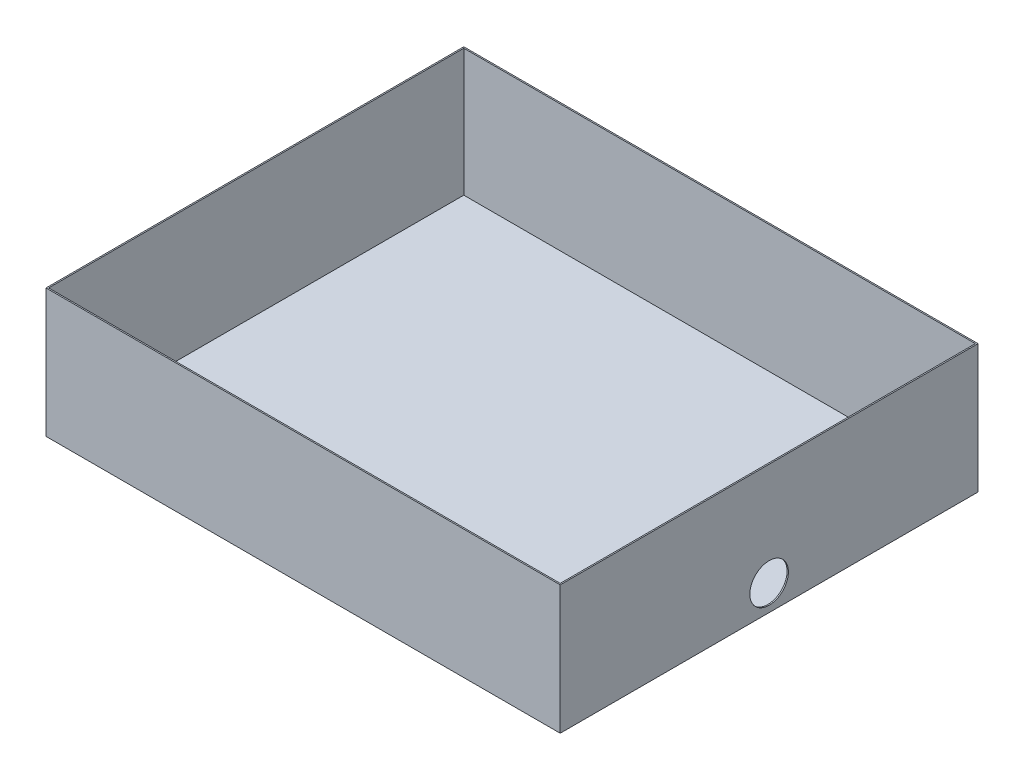
from build123d import *

# Parameters (mm, degrees)
SKETCH1_W           = 800
SKETCH1_H           = 650
BOSS_EXTRUDE1_DEPTH = 200
SKETCH2_W           = 796
SKETCH2_H           = 646
CUT_EXTRUDE1_DEPTH  = 198
CUT_EXTRUDE3_REACH  = 802
SKETCH4_R           = 30


with BuildPart() as part:
    # Sketch1 → Boss-Extrude1 (new body)
    with BuildSketch(Plane(origin=(0, 0, 0), x_dir=(1, 0, 0), z_dir=(0, 1, 0))):
        with Locations((400, 325)):
            Rectangle(SKETCH1_W, SKETCH1_H)
    extrude(amount=BOSS_EXTRUDE1_DEPTH)

    # Sketch2 → Cut-Extrude1 (cut)
    with BuildSketch(Plane(origin=(0, 200, 0), x_dir=(1, 0, 0), z_dir=(0, 1, 0))):
        with Locations((400, 325)):
            Rectangle(SKETCH2_W, SKETCH2_H)
    extrude(amount=-CUT_EXTRUDE1_DEPTH, mode=Mode.SUBTRACT)

    # Sketch4 → Cut-Extrude3 (cut, up to next)
    with BuildSketch(Plane(origin=(800, 0, 0), x_dir=(0, 0, -1), z_dir=(1, 0, 0)), mode=Mode.PRIVATE) as cut_extrude3_sk1:
        with Locations((325, 40)):
            Circle(SKETCH4_R)
    cut_extrude3_tool1 = extrude(cut_extrude3_sk1.sketch, amount=-CUT_EXTRUDE3_REACH, mode=Mode.PRIVATE) & part.part
    add(cut_extrude3_tool1.solids().sort_by_distance((800, 40, -325))[0], mode=Mode.SUBTRACT)


solid = part.part
